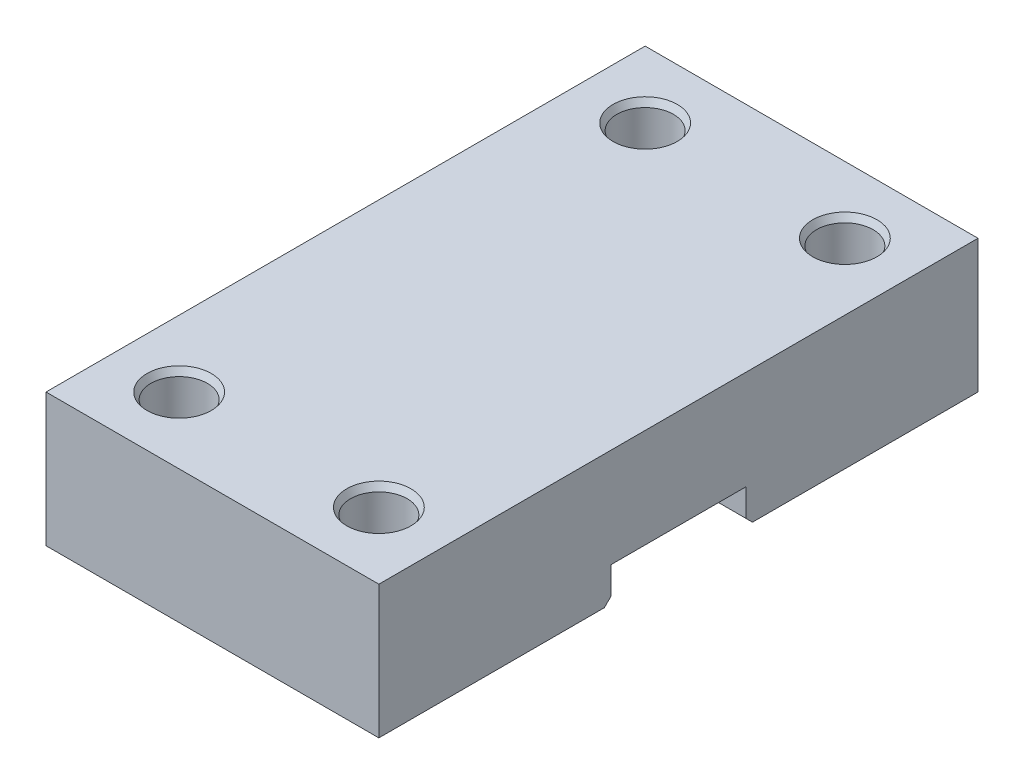
from build123d import *

# Parameters (mm, degrees)
SKETCH1_W               = 50
SKETCH1_H               = 90
BOSS_EXTRUDE1_DEPTH     = 20
SKETCH2_W               = 20.25
SKETCH2_H               = 5.1
CUT_EXTRUDE1_DEPTH      = 1
CUT_EXTRUDE1_DEPTH_BACK = 51
SKETCH3_R               = 4.25
CUT_EXTRUDE2_DEPTH      = 21
CHAMFER1_SIZE           = 1
CHAMFER1_SIZE2          = 0.577350269
CHAMFER1_PART_2_SIZE    = 1
CHAMFER1_PART_2_SIZE2   = 0.577350269
CHAMFER1_PART_3_SIZE    = 1
CHAMFER1_PART_3_SIZE2   = 0.577350269
CHAMFER1_PART_4_SIZE    = 1
CHAMFER1_PART_4_SIZE2   = 0.577350269
CHAMFER2_SIZE           = 1


with BuildPart() as part:
    # Sketch1 → Boss-Extrude1 (new body)
    with BuildSketch(Plane(origin=(0, 0, 0), x_dir=(1, 0, 0), z_dir=(0, 1, 0))):
        Rectangle(SKETCH1_W, SKETCH1_H)
    extrude(amount=BOSS_EXTRUDE1_DEPTH)

    # Sketch2 → Cut-Extrude1 (cut, two sides)
    with BuildSketch(Plane(origin=(25, 0, 0), x_dir=(0, 0, -1), z_dir=(1, 0, 0))) as cut_extrude1_sk:
        with Locations((0, 2.55)):
            Rectangle(SKETCH2_W, SKETCH2_H)
    extrude(amount=CUT_EXTRUDE1_DEPTH, mode=Mode.SUBTRACT)
    extrude(cut_extrude1_sk.sketch, amount=-CUT_EXTRUDE1_DEPTH_BACK, mode=Mode.SUBTRACT)

    # Sketch3 → Cut-Extrude2 (cut, through all)
    with BuildSketch(Plane.XZ):
        with Locations((-15, 35)):
            Circle(SKETCH3_R)
        with Locations((-15, -35)):
            Circle(SKETCH3_R)
        with Locations((15, 35)):
            Circle(SKETCH3_R)
        with Locations((15, -35)):
            Circle(SKETCH3_R)
    extrude(amount=-CUT_EXTRUDE2_DEPTH, mode=Mode.SUBTRACT)

    # Chamfer1
    chamfer1_edges = [part.edges().sort_by_distance(p)[0] for p in [
        (-19.25, 20, 35),
    ]]
    chamfer1_side = [part.faces().sort_by_distance(p)[0] for p in [
        (-19.25, 10, 35),
    ]]
    chamfer(chamfer1_edges, length=CHAMFER1_SIZE, length2=CHAMFER1_SIZE2, reference=chamfer1_side[0])

    # Chamfer1 part 2
    chamfer1_part_2_edges = [part.edges().sort_by_distance(p)[0] for p in [
        (10.75, 20, 35),
    ]]
    chamfer1_part_2_side = [part.faces().sort_by_distance(p)[0] for p in [
        (10.75, 10, 35),
    ]]
    chamfer(chamfer1_part_2_edges, length=CHAMFER1_PART_2_SIZE, length2=CHAMFER1_PART_2_SIZE2, reference=chamfer1_part_2_side[0])

    # Chamfer1 part 3
    chamfer1_part_3_edges = [part.edges().sort_by_distance(p)[0] for p in [
        (10.75, 20, -35),
    ]]
    chamfer1_part_3_side = [part.faces().sort_by_distance(p)[0] for p in [
        (10.75, 10, -35),
    ]]
    chamfer(chamfer1_part_3_edges, length=CHAMFER1_PART_3_SIZE, length2=CHAMFER1_PART_3_SIZE2, reference=chamfer1_part_3_side[0])

    # Chamfer1 part 4
    chamfer1_part_4_edges = [part.edges().sort_by_distance(p)[0] for p in [
        (-19.25, 20, -35),
    ]]
    chamfer1_part_4_side = [part.faces().sort_by_distance(p)[0] for p in [
        (-19.25, 10, -35),
    ]]
    chamfer(chamfer1_part_4_edges, length=CHAMFER1_PART_4_SIZE, length2=CHAMFER1_PART_4_SIZE2, reference=chamfer1_part_4_side[0])

    # Chamfer2
    chamfer2_edges = [part.edges().sort_by_distance(p)[0] for p in [
        (0, 0, -10.125),
        (0, 0, 10.125),
    ]]
    chamfer(chamfer2_edges, length=CHAMFER2_SIZE)


solid = part.part
